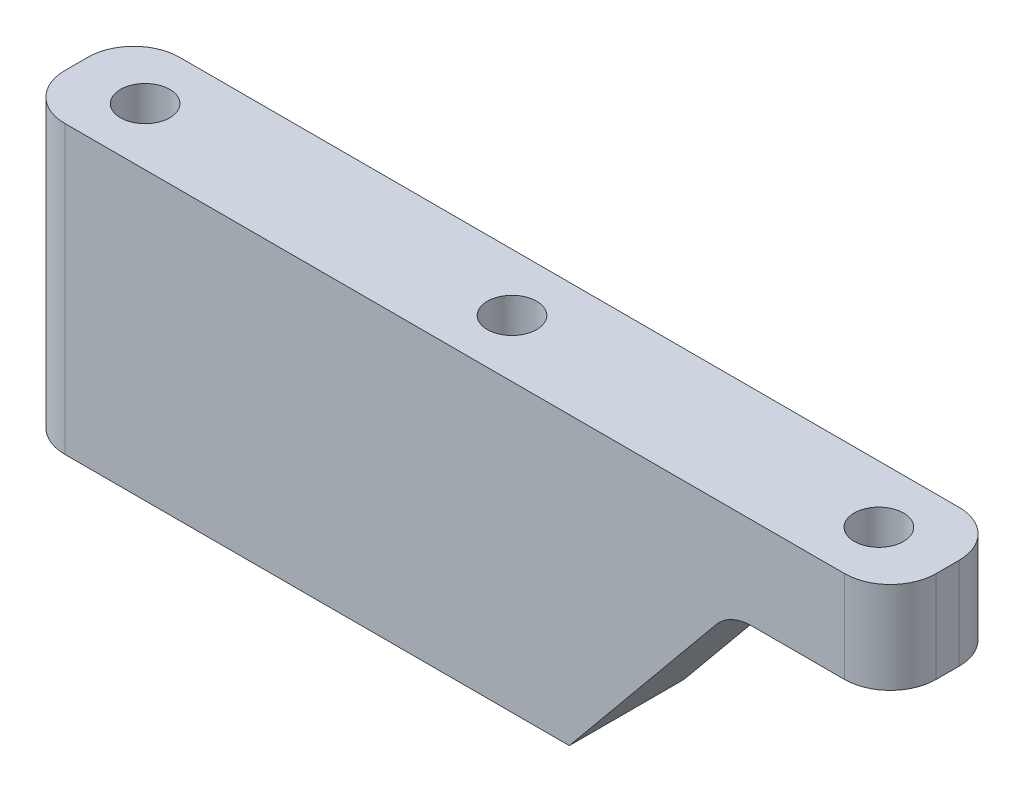
from build123d import *

# Parameters (mm, degrees)
SKETCH2_W           = 76
SKETCH2_H           = 10
SKETCH2_R           = 2.15
BOSS_EXTRUDE1_DEPTH = 25
CUT_EXTRUDE1_DEPTH  = 27
FILLET1_R           = 4


with BuildPart() as part:
    # Sketch2 → Boss-Extrude1 (new body)
    with BuildSketch(Plane(origin=(0, 0, 0), x_dir=(1, 0, 0), z_dir=(0, 1, 0))):
        Rectangle(SKETCH2_W, SKETCH2_H)
        with Locations((-32, 0)):
            Circle(SKETCH2_R, mode=Mode.SUBTRACT)
        Circle(SKETCH2_R, mode=Mode.SUBTRACT)
        with Locations((32, 0)):
            Circle(SKETCH2_R, mode=Mode.SUBTRACT)
    extrude(amount=BOSS_EXTRUDE1_DEPTH)

    # Sketch3 → Cut-Extrude1 (cut)
    with BuildSketch(Plane.XY.offset(5)):
        Polygon((38, 17), (24, 17), (10, 0), (38, 0), align=None)
    extrude(amount=-CUT_EXTRUDE1_DEPTH, mode=Mode.SUBTRACT)

    # Fillet1
    fillet1_edges = [part.edges().sort_by_distance(p)[0] for p in [
        (24, 17, 0),
        (38, 21, 5),
        (-38, 12.5, 5),
        (-38, 12.5, -5),
        (38, 21, -5),
    ]]
    fillet(fillet1_edges, radius=FILLET1_R)


solid = part.part
